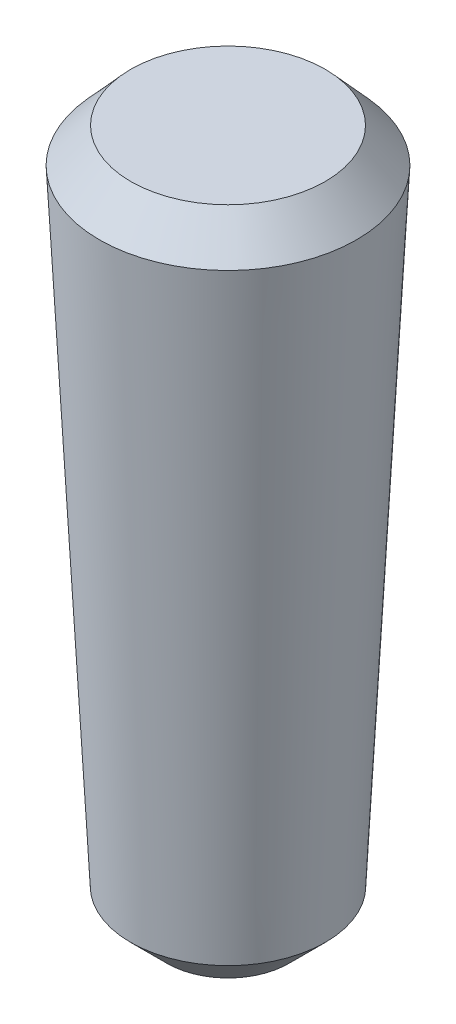
from build123d import *
from OCP.BRepFilletAPI import BRepFilletAPI_MakeChamfer

# Parameters (mm, degrees)
SKETCH2_R        = 1.875
SKETCH1_R        = 1.375
CHAMFER1_SIZE    = 0.5
CHAMFER1_SIZE2   = 0.526973274
CHAMFER1_SIZE2_2 = 0.476785343


with BuildPart() as part:
    # Sketch2 → Loft1 section 0
    with BuildSketch(Plane(origin=(0, 10, 0), x_dir=(1, 0, 0), z_dir=(0, 1, 0))):
        Circle(SKETCH2_R)
    # Sketch1 → Loft1 section 1
    with BuildSketch(Plane(origin=(0, 0, 0), x_dir=(1, 0, 0), z_dir=(0, 1, 0))):
        Circle(SKETCH1_R)
    loft()

    # Chamfer1: one chamfer whose edges measure the first distance from different faces: ONE call of the kernel's chamfer builder (chamfer() names one face for all edges)
    chamfer1_edges_1 = [part.edges().sort_by_distance(p)[0] for p in [
        (-1.375, 0, 0),
    ]]
    chamfer1_side_1 = [part.faces().sort_by_distance(p)[0] for p in [
        (0, 0, 0),
    ]]
    chamfer1_edges_2 = [part.edges().sort_by_distance(p)[0] for p in [
        (-1.875, 10, 0),
    ]]
    chamfer1_side_2 = [part.faces().sort_by_distance(p)[0] for p in [
        (-1.625, 5, 0),
    ]]
    chamfer1 = BRepFilletAPI_MakeChamfer(part.part.solid().wrapped)
    for e in chamfer1_edges_1:
        chamfer1.Add(CHAMFER1_SIZE, CHAMFER1_SIZE2, e.wrapped, chamfer1_side_1[0].wrapped)  # the first distance lies on this face
    for e in chamfer1_edges_2:
        chamfer1.Add(CHAMFER1_SIZE, CHAMFER1_SIZE2_2, e.wrapped, chamfer1_side_2[0].wrapped)  # the first distance lies on this face
    add(Compound.cast(chamfer1.Shape()), mode=Mode.REPLACE)


solid = part.part
